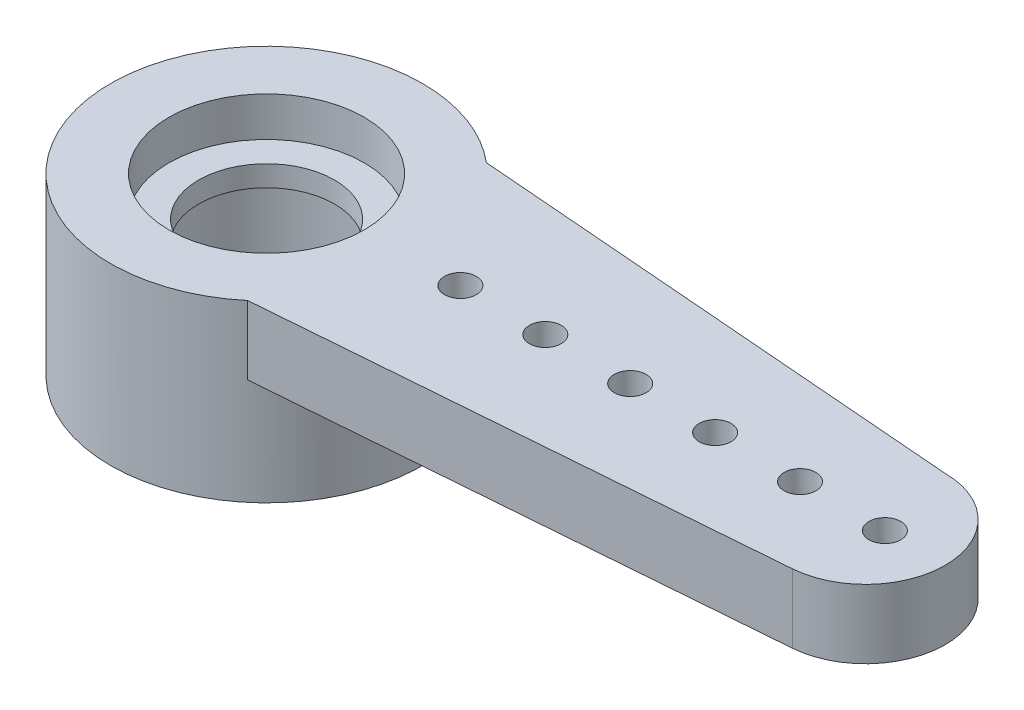
from build123d import *

# Parameters (mm, degrees)
BOSS_EXTRUDE1_DEPTH = 1.62
SKETCH2_R           = 3.675
BOSS_EXTRUDE2_DEPTH = 2.5
SKETCH3_R           = 2.3
SKETCH3_R_2         = 1.6
CUT_EXTRUDE1_DEPTH  = 2.7
SKETCH4_R           = 1.6
CUT_EXTRUDE2_DEPTH  = 4.12
SKETCH5_R           = 2.3
CUT_EXTRUDE3_DEPTH  = 0.93
SKETCH7_R           = 0.375
CUT_EXTRUDE4_DEPTH  = 1.62


with BuildPart() as part:
    # Sketch1 → Boss-Extrude1 (new body)
    with BuildSketch(Plane(origin=(0, 0, 0), x_dir=(1, 0, 0), z_dir=(0, 1, 0))):
        with BuildLine():
            Line((-30.04567513, 12.821055753), (-18.302594635, 11.884771872))
            ThreePointArc((-18.302594635, 11.884771872), (-16.429062652, 10.083953465), (-18.15434761, 8.140641642))
            Line((-18.15434761, 8.140641642), (-30.046970978, 7.197397481))
            ThreePointArc((-30.046970978, 7.197397481), (-36.087594537, 10.010618695), (-30.04567513, 12.821055753))
        make_face()
    extrude(amount=BOSS_EXTRUDE1_DEPTH)

    # Sketch2 → Boss-Extrude2 (add)
    with BuildSketch(Plane.XZ):
        with Locations((-32.412594635, -10.009771872)):
            Circle(SKETCH2_R)
    extrude(amount=BOSS_EXTRUDE2_DEPTH)

    # Sketch3 → Cut-Extrude1 (cut)
    with BuildSketch(Plane.XZ.offset(2.5)):
        with Locations((-32.412594635, -10.009771872)):
            Circle(SKETCH3_R)
        with Locations((-32.412594635, -10.009771872)):
            Circle(SKETCH3_R_2, mode=Mode.SUBTRACT)
    extrude(amount=-CUT_EXTRUDE1_DEPTH, mode=Mode.SUBTRACT)

    # Sketch4 → Cut-Extrude2 (cut)
    with BuildSketch(Plane.XZ.offset(2.5)):
        with Locations((-32.412594635, -10.009771872)):
            Circle(SKETCH4_R)
    extrude(amount=-CUT_EXTRUDE2_DEPTH, mode=Mode.SUBTRACT)

    # Sketch5 → Cut-Extrude3 (cut)
    with BuildSketch(Plane(origin=(0, 1.62, 0), x_dir=(1, 0, 0), z_dir=(0, 1, 0))):
        with Locations((-32.412594635, 10.009771872)):
            Circle(SKETCH5_R)
    extrude(amount=-CUT_EXTRUDE3_DEPTH, mode=Mode.SUBTRACT)

    # Sketch7 → Cut-Extrude4 (cut)
    with BuildSketch(Plane.XZ):
        with Locations((-27.846278089, -10.008997382)):
            Circle(SKETCH7_R)
        with Locations((-25.846278089, -10.008997382)):
            Circle(SKETCH7_R)
        with Locations((-23.846278089, -10.008997382)):
            Circle(SKETCH7_R)
        with Locations((-21.846278089, -10.008997382)):
            Circle(SKETCH7_R)
        with Locations((-19.846278089, -10.008997382)):
            Circle(SKETCH7_R)
        with Locations((-17.846278089, -10.008997382)):
            Circle(SKETCH7_R)
    extrude(amount=-CUT_EXTRUDE4_DEPTH, mode=Mode.SUBTRACT)


solid = part.part
